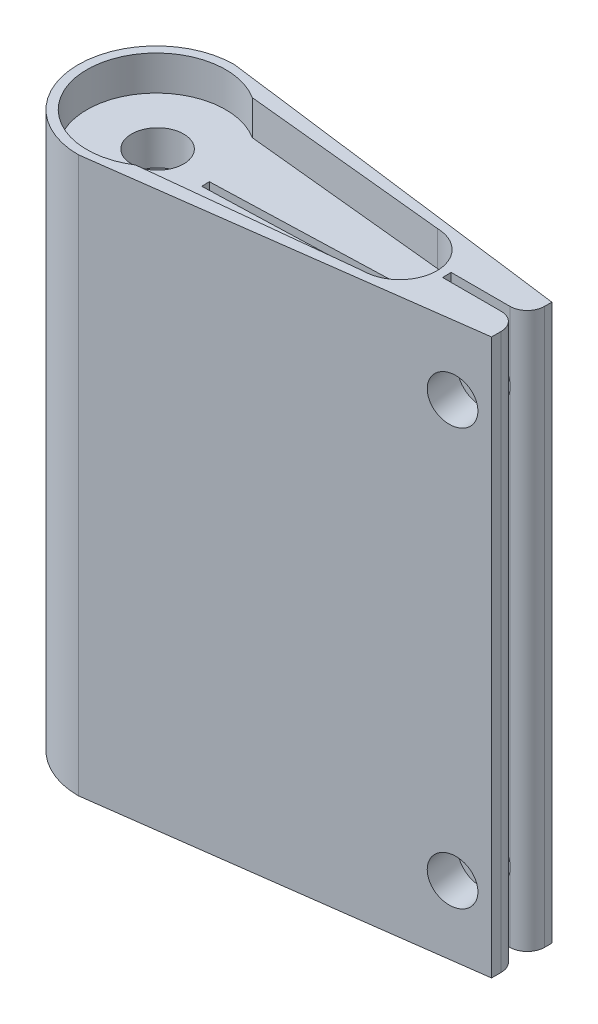
from build123d import *

# Parameters (mm, degrees)
SKETCH2_R           = 1.5
BOSS_EXTRUDE1_DEPTH = 30
BOSS_EXTRUDE2_DEPTH = 32
FILLET3_R           = 1
CUT_EXTRUDE1_DEPTH  = 13.5
SKETCH5_R           = 1.3
CUT_EXTRUDE2_DEPTH  = 46.300984841
SKETCH6_R           = 3
CUT_EXTRUDE3_DEPTH  = 28


with BuildPart() as part:
    # Sketch2 → Boss-Extrude1 (new body)
    with BuildSketch(Plane(origin=(0, 0, 0), x_dir=(1, 0, 0), z_dir=(0, 1, 0))):
        with BuildLine():
            Line((-12.939762178, 2.094266176), (-24.821781773, 3.29179515))
            ThreePointArc((-24.821781773, 3.29179515), (-30.987291256, -0.071668068), (-24.821747911, -3.435069212))
            Line((-24.821747911, -3.435069212), (-12.987160246, -2.166440487))
            ThreePointArc((-12.987160246, -2.166440487), (-10.8566751, -0.059524017), (-12.939762178, 2.094266176))
        make_face()
        with Locations((-26.987114413, 0)):
            Circle(SKETCH2_R, mode=Mode.SUBTRACT)
    extrude(amount=BOSS_EXTRUDE1_DEPTH)

    # Sketch2_3 → Boss-Extrude2 (add)
    with BuildSketch(Plane(origin=(0, 0, 0), x_dir=(1, 0, 0), z_dir=(0, 1, 0))):
        with BuildLine():
            Line((-5.980021524, -1.757335699), (-5.980297938, -0.2))
            Line((-5.980297938, -0.2), (-10.355629468, -0.2))
            Line((-10.355629468, -0.2), (-10.371987074, 0.3))
            Line((-10.371987074, 0.3), (-5.980159731, 0.3))
            Line((-5.980159731, 0.3), (-5.980159731, 1.71899167))
            Line((-5.980159731, 1.71899167), (-26.987114411, 4.428185187))
            ThreePointArc((-26.987114411, 4.428185187), (-31.48694753, -0.071647931), (-26.987114411, -4.57148105))
            Line((-26.987114411, -4.57148105), (-5.980021524, -1.757335699))
        make_face()
        with BuildLine():
            Line((-12.987160246, -2.166440487), (-24.821747911, -3.435069212))
            ThreePointArc((-24.821747911, -3.435069212), (-30.987291256, -0.071668068), (-24.821781773, 3.29179515))
            Line((-24.821781773, 3.29179515), (-12.939762178, 2.094266176))
            ThreePointArc((-12.939762178, 2.094266176), (-10.8566751, -0.059524017), (-12.987160246, -2.166440487))
        make_face(mode=Mode.SUBTRACT)
    extrude(amount=BOSS_EXTRUDE2_DEPTH)

    # Fillet3
    fillet3_edges = [part.edges().sort_by_distance(p)[0] for p in [
        (-5.980297938, 16, 0.2),
        (-5.980159731, 16, -0.3),
    ]]
    fillet(fillet3_edges, radius=FILLET3_R)

    # Sketch4 → Cut-Extrude1 (cut)
    with BuildSketch(Plane(origin=(-10.351093889, 0, 0.338638235), x_dir=(-0.03269771907792328, 0, -0.9994652866243536), z_dir=(0.9994652866243536, 0, -0.03269771907792328))):
        Polygon((0.190205723, 30), (0.138712406, 16), (0.190205723, 2), (0.638979906, 2), (0.634009108, 16), (0.638979906, 30), align=None)
    extrude(amount=-CUT_EXTRUDE1_DEPTH, mode=Mode.SUBTRACT)

    # Sketch5 → Cut-Extrude2 (cut, through all)
    with BuildSketch(Plane(origin=(0.125841463, 0, 0.939384066), x_dir=(0.9911461251188364, 0, -0.1327755951292104), z_dir=(0.1327755951292104, 0, 0.9911461251188365))):
        with Locations((-8.160406455, 28)):
            Circle(SKETCH5_R)
        with Locations((-8.160406455, 4)):
            Circle(SKETCH5_R)
    extrude(amount=-CUT_EXTRUDE2_DEPTH, mode=Mode.SUBTRACT)

    # Sketch6 → Cut-Extrude3 (cut)
    with BuildSketch(Plane.XZ):
        with Locations((-26.987114413, 0)):
            Circle(SKETCH6_R)
    extrude(amount=-CUT_EXTRUDE3_DEPTH, mode=Mode.SUBTRACT)


solid = part.part
